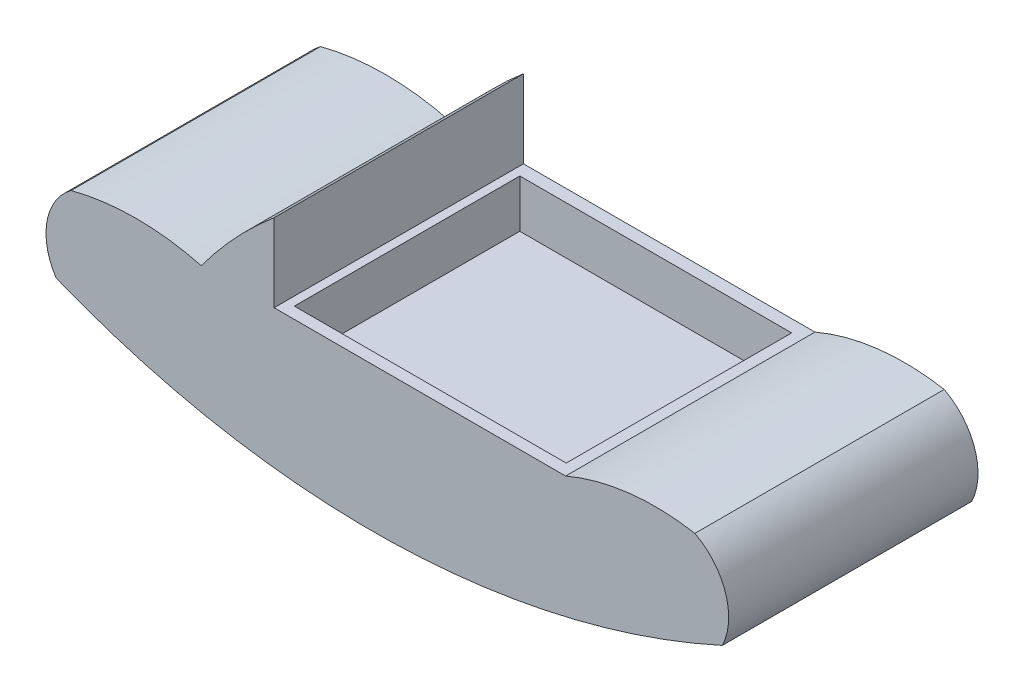
from build123d import *

# Parameters (mm, degrees)
BOSS_EXTRUDE2_DEPTH     = 121.666
SKETCH4_W               = 132.653422834
SKETCH4_H               = 110.004689212
CUT_EXTRUDE1_DEPTH      = 34.29
CUT_EXTRUDE1_DEPTH_BACK = 23.368


with BuildPart() as part:
    # Sketch2 → Boss-Extrude2 (new body)
    with BuildSketch(Plane.XY):
        with BuildLine():
            Line((88.9, 0), (-53.34, 0))
            Line((-53.34, 0), (-53.34, 38.074701195))
            ThreePointArc((-53.34, 38.074701195), (-72.236919303, 20.080501277), (-88.9, 0))
            ThreePointArc((-88.9, 0), (-120.65, 4.094872711), (-152.4, 0))
            ThreePointArc((-152.4, 0), (-164.191323146, -18.853572603), (-159.736653386, -40.64))
            ThreePointArc((-159.736653386, -40.64), (3.572889221, -70.366104417), (165.383346614, -33.33876494))
            ThreePointArc((165.383346614, -33.33876494), (166.92020334, -10.301221175), (151.978855147, 7.30123506))
            ThreePointArc((151.978855147, 7.30123506), (119.904882148, 8.268810644), (88.9, 0))
        make_face()
    extrude(amount=BOSS_EXTRUDE2_DEPTH)

    # Sketch4 → Cut-Extrude1 (cut, two sides)
    with BuildSketch(Plane(origin=(0, 0, 0), x_dir=(1, 0, 0), z_dir=(0, 1, 0))) as cut_extrude1_sk:
        with Locations((17.235431011, -61.044907142)):
            Rectangle(SKETCH4_W, SKETCH4_H)
    extrude(amount=CUT_EXTRUDE1_DEPTH, mode=Mode.SUBTRACT)
    extrude(cut_extrude1_sk.sketch, amount=-CUT_EXTRUDE1_DEPTH_BACK, mode=Mode.SUBTRACT)


solid = part.part
